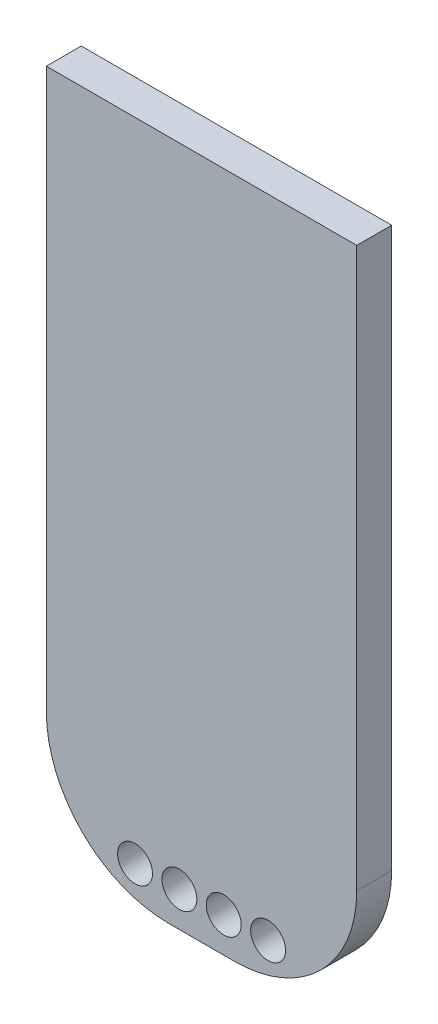
from build123d import *

# Parameters (mm, degrees)
SKETCH1_W           = 17.78
SKETCH1_H           = 39.02
BOSS_EXTRUDE1_DEPTH = 2
SKETCH2_R           = 1
CUT_EXTRUDE5_DEPTH  = 10
FILLET4_R           = 7


with BuildPart() as part:
    # Sketch1 → Boss-Extrude1 (new body)
    with BuildSketch(Plane.XY):
        with Locations((8.89, 19.51)):
            Rectangle(SKETCH1_W, SKETCH1_H)
    extrude(amount=BOSS_EXTRUDE1_DEPTH)

    # Sketch2 → Cut-Extrude5 (cut)
    with BuildSketch(Plane.XY.offset(2)):
        with Locations((5.081291963, 2)):
            Circle(SKETCH2_R)
        with Locations((7.621291963, 2)):
            Circle(SKETCH2_R)
        with Locations((10.161291963, 2)):
            Circle(SKETCH2_R)
        with Locations((12.701291963, 2)):
            Circle(SKETCH2_R)
    extrude(amount=-CUT_EXTRUDE5_DEPTH, mode=Mode.SUBTRACT)

    # Fillet4
    fillet4_edges = [part.edges().sort_by_distance(p)[0] for p in [
        (17.78, 0, 1),
        (0, 0, 1),
    ]]
    fillet(fillet4_edges, radius=FILLET4_R)


solid = part.part
